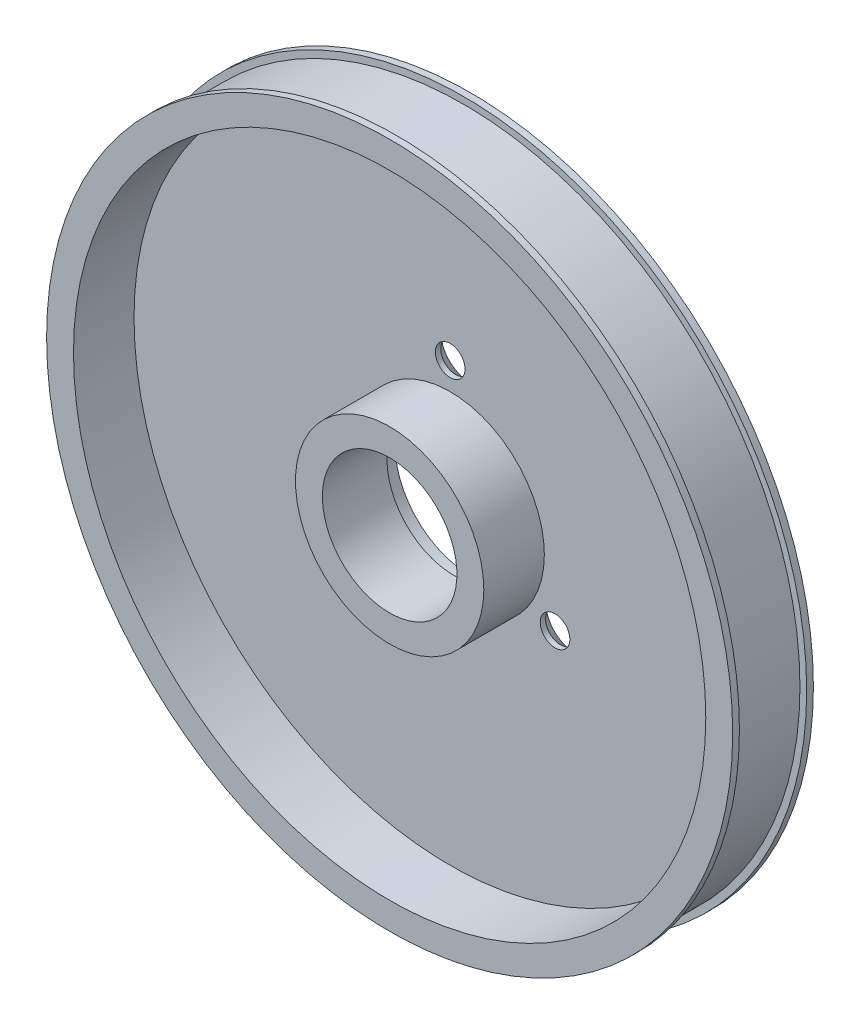
from build123d import *

# Parameters (mm, degrees)
M42_CLEARANCE_HOLE1_D                           = 47
M42_CLEARANCE_HOLE1_DEPTH                       = 4.5
SKETCH4_W                                       = 7
SKETCH4_H                                       = 4.5
CSK_FOR_M2_FLAT_HEAD_MACHINE_SCREW1_D           = 2.2
CSK_FOR_M2_FLAT_HEAD_MACHINE_SCREW1_DEPTH       = 6
CSK_FOR_M2_FLAT_HEAD_MACHINE_SCREW1_CSINK_D     = 4.4
CSK_FOR_M2_FLAT_HEAD_MACHINE_SCREW1_CSINK_ANGLE = 90
CBORE_FOR_M8_HEX_HEAD_BOLT1_D                   = 10
CBORE_FOR_M8_HEX_HEAD_BOLT1_DEPTH               = 6
CBORE_FOR_M8_HEX_HEAD_BOLT1_CBORE_D             = 11.2
CBORE_FOR_M8_HEX_HEAD_BOLT1_CBORE_DEPTH         = 1.2


with BuildPart() as part:
    # Sketch1 → Revolve1 (revolve)
    with BuildSketch(Plane(origin=(0, 0, 0), x_dir=(1, 0, 0), z_dir=(0, 1, 0))):
        Polygon((25.5, 0), (0, 0), (0, -6), (25.5, -6), (25.5, -5.5), (25, -5.5), (25, -0.5), (25.5, -0.5), align=None)
    revolve(axis=Axis((0, 0, 0), (0, 0, 1)))

    # M42 Clearance Hole1
    with Locations(Plane.XY.offset(6)):
        with Locations((0, 0)):
            Hole(M42_CLEARANCE_HOLE1_D / 2, depth=M42_CLEARANCE_HOLE1_DEPTH)

    # Sketch4 → Revolve2 (revolve)
    with BuildSketch(Plane(origin=(0, 0, 0), x_dir=(1, 0, 0), z_dir=(0, 1, 0))):
        with Locations((3.5, -3.75)):
            Rectangle(SKETCH4_W, SKETCH4_H)
    revolve(axis=Axis((0, 0, 1.5), (0, 0, 1)))

    # CSK for M2 Flat Head Machine Screw1
    with Locations(Plane(origin=(0, 0, 0), x_dir=(-1, 0, 0), z_dir=(0, 0, -1))):
        with Locations((-7.794228634, -4.5), (7.794228634, -4.5), (0, 9)):
            CounterSinkHole(CSK_FOR_M2_FLAT_HEAD_MACHINE_SCREW1_D / 2, CSK_FOR_M2_FLAT_HEAD_MACHINE_SCREW1_CSINK_D / 2, depth=CSK_FOR_M2_FLAT_HEAD_MACHINE_SCREW1_DEPTH, counter_sink_angle=CSK_FOR_M2_FLAT_HEAD_MACHINE_SCREW1_CSINK_ANGLE)

    # CBORE for M8 Hex Head Bolt1
    with Locations(Plane(origin=(0, 0, 0), x_dir=(-1, 0, 0), z_dir=(0, 0, -1))):
        with Locations((0, 0)):
            CounterBoreHole(CBORE_FOR_M8_HEX_HEAD_BOLT1_D / 2, CBORE_FOR_M8_HEX_HEAD_BOLT1_CBORE_D / 2, CBORE_FOR_M8_HEX_HEAD_BOLT1_CBORE_DEPTH, depth=CBORE_FOR_M8_HEX_HEAD_BOLT1_DEPTH)


solid = part.part
